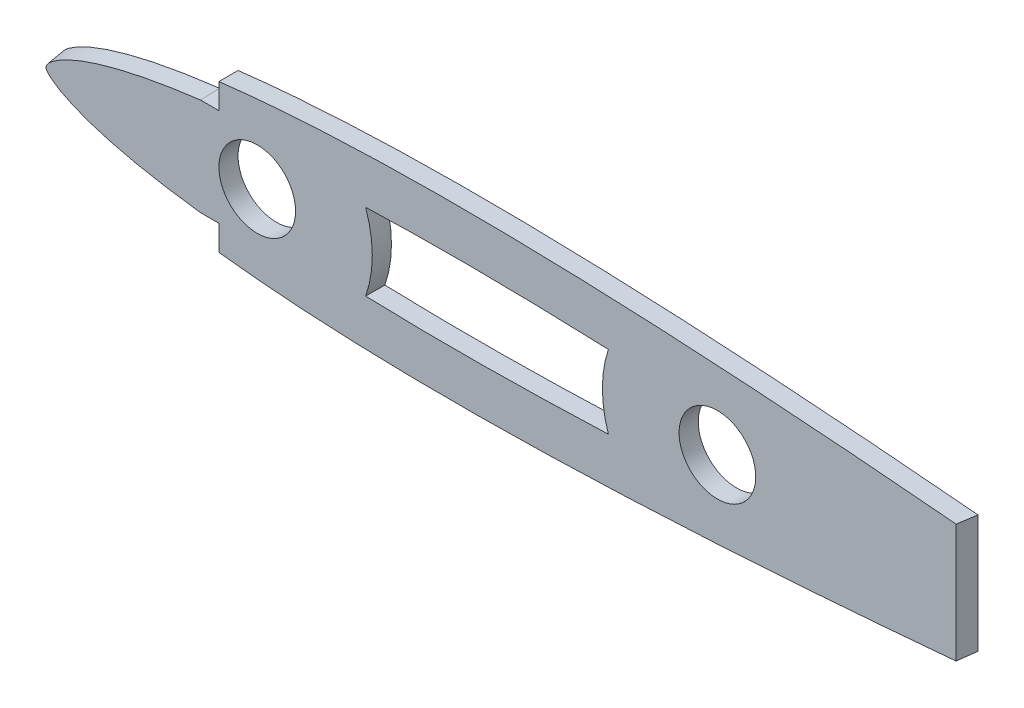
from build123d import *

# Parameters (mm, degrees)
BOSS_EXTRUDE1_DEPTH     = 3.175
SKETCH2_R               = 6.35
CUT_EXTRUDE1_DEPTH      = 3.175
CUT_EXTRUDE2_DEPTH      = 15.229125104
CUT_EXTRUDE2_DEPTH_BACK = 15.229125104
CUT_EXTRUDE3_DEPTH      = 7.62


with BuildPart() as part:
    # Sketch1 → Boss-Extrude1 (new body)
    with BuildSketch(Plane.XY):
        with BuildLine():
            add(Edge.make_bspline(
                [(237.0836, 0.298725336), (236.995594177, 0.372475408), (236.426976915, 0.302841036), (235.414414738, 0.587878253), (233.557510406, 0.764057302), (231.055978259, 1.142159154), (227.833630131, 1.564095564), (223.947681725, 2.084112793), (219.408243114, 2.671942868), (214.248186401, 3.326415443), (208.497669056, 4.03606524), (202.192664292, 4.791288168), (195.371926847, 5.582717259), (188.077459081, 6.399577403), (180.354259346, 7.2318954), (172.249998357, 8.069333754), (163.814621862, 8.901083193), (155.10015976, 9.715468455), (146.160279484, 10.50179834), (137.050196099, 11.246926821), (127.825887085, 11.938704549), (118.544307176, 12.564288117), (109.262643889, 13.110597113), (100.038037253, 13.563829729), (90.927458146, 13.911900095), (81.986813488, 14.143452851), (73.27135464, 14.247178081), (64.83463449, 14.214844108), (56.728667619, 14.040205364), (49.003349951, 13.718834947), (41.706232299, 13.249892202), (34.882163012, 12.634788148), (28.572900537, 11.878326773), (22.816901851, 10.986944444), (17.649046914, 9.969950888), (13.099625234, 8.838845522), (9.194488598, 7.604658034), (5.953477664, 6.278883166), (3.386928106, 4.870490409), (1.49878923, 3.376700029), (0.289451642, 1.761373844), (-0.134894757, 0), (0.289451642, -1.761373844), (1.49878923, -3.376700029), (3.386928106, -4.870490409), (5.953477664, -6.278883166), (9.194488598, -7.604658034), (13.099625234, -8.838845522), (17.649046914, -9.969950888), (22.816901851, -10.986944444), (28.572900537, -11.878326773), (34.882163012, -12.634788148), (41.706232299, -13.249892202), (49.003349951, -13.718834947), (56.728667619, -14.040205364), (64.83463449, -14.214844108), (73.27135464, -14.247178081), (81.986813488, -14.143452851), (90.927458146, -13.911900095), (100.038037253, -13.563829729), (109.262643889, -13.110597113), (118.544307176, -12.564288117), (127.825887085, -11.938704549), (137.050196099, -11.246926821), (146.160279484, -10.50179834), (155.10015976, -9.715468455), (163.814621862, -8.901083193), (172.249998357, -8.069333754), (180.354259346, -7.2318954), (188.077459081, -6.399577403), (195.371926847, -5.582717259), (202.192664292, -4.791288168), (208.497669056, -4.03606524), (214.248186401, -3.326415443), (219.408243114, -2.671942868), (223.947681725, -2.084112793), (227.833630131, -1.564095564), (231.055978259, -1.142159154), (233.557510406, -0.764057302), (235.414414738, -0.587878253), (236.426976915, -0.302841036), (237.226122795, -0.400706552), (237.226122795, 0.179289302), (237.0836, 0.298725336)],
                knots=[0, 0, 0, 0, 0.000762215, 0.003044706, 0.006832246, 0.012101176, 0.018817536, 0.026939455, 0.036414848, 0.047184629, 0.059180413, 0.072327874, 0.086544061, 0.10174058, 0.117823336, 0.134691452, 0.152240154, 0.17036129, 0.188941008, 0.207865435, 0.227016078, 0.246275696, 0.265524943, 0.284644966, 0.303520118, 0.322034575, 0.340078353, 0.357542593, 0.374325482, 0.390329891, 0.40546389, 0.419643801, 0.432793371, 0.444843817, 0.455737921, 0.465428653, 0.47388632, 0.481101634, 0.487101684, 0.491975368, 0.495930678, 0.499382808, 0.502834938, 0.506790248, 0.511663932, 0.517663982, 0.524879296, 0.533336963, 0.543027695, 0.553921799, 0.565972245, 0.579121815, 0.593301726, 0.608435725, 0.624440134, 0.641223023, 0.658687263, 0.676731041, 0.695245498, 0.71412065, 0.733240673, 0.75248992, 0.771749538, 0.790900181, 0.809824608, 0.828404326, 0.846525462, 0.864074164, 0.88094228, 0.897025036, 0.912221555, 0.926437743, 0.939585203, 0.951580988, 0.962350768, 0.971826161, 0.979948081, 0.98666444, 0.991933371, 0.99572091, 0.998003402, 0.998765616, 1, 1, 1, 1], degree=3))
        make_face()
    extrude(amount=BOSS_EXTRUDE1_DEPTH)

    # Sketch2 → Cut-Extrude1 (cut)
    with BuildSketch(Plane.XY.offset(3.175)):
        with Locations((38.1, 0)):
            Circle(SKETCH2_R)
        with Locations((114.3, 0)):
            Circle(SKETCH2_R)
    extrude(amount=-CUT_EXTRUDE1_DEPTH, mode=Mode.SUBTRACT)

    # Sketch3 → Cut-Extrude2 (cut, two sides)
    with BuildSketch(Plane(origin=(0, 0, 0), x_dir=(1, 0, 0), z_dir=(0, 1, 0))) as cut_extrude2_sk:
        Polygon((154.274292451, 0), (153.827643764, -3.175), (237.190492096, -3.175), (237.190492096, 0), align=None)
    extrude(amount=CUT_EXTRUDE2_DEPTH, mode=Mode.SUBTRACT)
    extrude(cut_extrude2_sk.sketch, amount=-CUT_EXTRUDE2_DEPTH_BACK, mode=Mode.SUBTRACT)

    # Sketch6 → Cut-Loft1 section 0
    with BuildSketch(Plane.XY.offset(3.175)):
        with BuildLine():
            Line((31.75, 8.076408981), (31.75, 11.683250037))
            Line((31.75, 11.683250037), (31.75, 18.395885889))
            Line((31.75, 18.395885889), (-8.998418256, 14.186873402))
            Line((-8.998418256, 14.186873402), (-8.032236021, -19.061162304))
            Line((-8.032236021, -19.061162304), (31.75, -17.664488176))
            Line((31.75, -17.664488176), (31.75, -11.683250037))
            Line((31.75, -11.683250037), (31.75, -8.076408982))
            Line((31.75, -8.076408982), (28.702, -8.076408982))
            add(Edge.make_bspline(
                [(28.702, 8.076408981), (28.062019842, 7.997428017), (26.781360323, 7.83190678), (24.863238423, 7.559576486), (22.952864289, 7.261817641), (21.053229662, 6.936585888), (19.16878625, 6.582266966), (17.301352642, 6.194891801), (15.452394184, 5.770523851), (13.933846318, 5.382610192), (12.734807014, 5.049324169), (11.845778194, 4.787008043), (10.968295358, 4.511299981), (10.104114856, 4.221132537), (9.254625692, 3.915388001), (8.425053114, 3.594578064), (7.620756036, 3.259288164), (6.846465326, 2.908873288), (6.109521351, 2.54404498), (5.415085904, 2.161886878), (4.771732283, 1.761162286), (4.200618093, 1.360175223), (3.806381168, 1.039757171), (3.546177048, 0.785599694), (3.383920596, 0.598121849), (3.254767765, 0.412598836), (3.174243399, 0.254294099), (3.130379566, 0.1138318), (3.117983008, 3.16e-07), (3.130380113, -0.113832551), (3.174242347, -0.254293127), (3.254769825, -0.41260053), (3.383916396, -0.598118576), (3.546175023, -0.785598191), (3.806491944, -1.039841143), (4.20055318, -1.360126113), (4.77176705, -1.761188423), (5.41506381, -2.161870561), (6.109540545, -2.544058683), (6.846443726, -2.908858743), (7.620785984, -3.259307593), (8.424980153, -3.594531648), (9.25458748, -3.915363972), (10.104136109, -4.221145998), (10.968310445, -4.511309444), (11.845765894, -4.787000103), (12.734797781, -5.049319704), (13.933888924, -5.382621972), (15.4523656, -5.770516248), (17.301363518, -6.194894525), (19.168788744, -6.582267832), (21.053210036, -6.936580559), (22.952903047, -7.261827785), (24.863140664, -7.559551063), (26.781311277, -7.831894211), (28.062019842, -7.997428017), (28.702, -8.076408982)],
                knots=[0, 0, 0, 0, 0.03125, 0.0625, 0.09375, 0.125, 0.15625, 0.1875, 0.21875, 0.25, 0.265625, 0.28125, 0.296875, 0.3125, 0.328125, 0.34375, 0.359375, 0.375, 0.390625, 0.40625, 0.421875, 0.4375, 0.453125, 0.4609375, 0.46875, 0.4765625, 0.484375, 0.4921875, 0.5, 0.5078125, 0.515625, 0.5234375, 0.53125, 0.5390625, 0.546875, 0.5625, 0.578125, 0.59375, 0.609375, 0.625, 0.640625, 0.65625, 0.671875, 0.6875, 0.703125, 0.71875, 0.734375, 0.75, 0.78125, 0.8125, 0.84375, 0.875, 0.90625, 0.9375, 0.96875, 1, 1, 1, 1], degree=3))
            Line((28.702, 8.076408981), (31.75, 8.076408981))
        make_face()
    # Sketch5 → Cut-Loft1 section 1
    with BuildSketch(Plane(origin=(0, 0, 0), x_dir=(-1, 0, 0), z_dir=(0, 0, -1))):
        with BuildLine():
            Line((-31.75, -11.773629767), (-31.75, -8.172962021))
            Line((-31.75, -8.172962021), (-28.702, -8.172962021))
            add(Edge.make_bspline(
                [(-28.702, 8.17296202), (-28.04991232, 8.094156153), (-26.745045473, 7.928885379), (-24.790625464, 7.656596528), (-22.843952156, 7.358509388), (-20.907993005, 7.032534185), (-18.987137813, 6.677003012), (-17.083250909, 6.287895965), (-15.197789513, 5.861217163), (-13.648800631, 5.470809812), (-12.425346674, 5.135128731), (-11.518003122, 4.870795331), (-10.622183079, 4.592820857), (-9.739660488, 4.300116815), (-8.871825969, 3.991542258), (-8.023884998, 3.667528855), (-7.201182529, 3.328585226), (-6.408478992, 2.973975846), (-5.653156453, 2.604323149), (-4.940474095, 2.216549268), (-4.279203879, 1.809302193), (-3.690786556, 1.400484278), (-3.283034517, 1.072052932), (-3.013354261, 0.810752852), (-2.845020129, 0.61774711), (-2.710958875, 0.426579544), (-2.627372313, 0.263337315), (-2.58177414, 0.117962243), (-2.568858472, 3.28e-07), (-2.581774708, -0.117963026), (-2.627371214, -0.263336298), (-2.710961028, -0.426581314), (-2.845015751, -0.617743699), (-3.01335214, -0.810751279), (-3.283150094, -1.072140545), (-3.690718878, -1.400433069), (-4.27924005, -1.809329397), (-4.940451244, -2.216532371), (-5.653176086, -2.604337198), (-6.408457303, -2.973961207), (-7.201212263, -3.32860454), (-8.023812968, -3.667483017), (-8.871788374, -3.991518624), (-9.739681391, -4.300130053), (-10.622197985, -4.592830206), (-11.517990976, -4.870787488), (-12.425337452, -5.135124325), (-13.648844495, -5.470821714), (-15.197759965, -5.861209465), (-17.083262354, -6.287898751), (-18.987139884, -6.677003815), (-20.907973868, -7.032528958), (-22.843990245, -7.358519372), (-24.790529171, -7.656571477), (-26.744997097, -7.928872987), (-28.04991232, -8.094156153), (-28.702, -8.172962021)],
                knots=[0, 0, 0, 0, 0.03125, 0.0625, 0.09375, 0.125, 0.15625, 0.1875, 0.21875, 0.25, 0.265625, 0.28125, 0.296875, 0.3125, 0.328125, 0.34375, 0.359375, 0.375, 0.390625, 0.40625, 0.421875, 0.4375, 0.453125, 0.4609375, 0.46875, 0.4765625, 0.484375, 0.4921875, 0.5, 0.5078125, 0.515625, 0.5234375, 0.53125, 0.5390625, 0.546875, 0.5625, 0.578125, 0.59375, 0.609375, 0.625, 0.640625, 0.65625, 0.671875, 0.6875, 0.703125, 0.71875, 0.734375, 0.75, 0.78125, 0.8125, 0.84375, 0.875, 0.90625, 0.9375, 0.96875, 1, 1, 1, 1], degree=3))
            Line((-28.702, 8.17296202), (-31.75, 8.17296202))
            Line((-31.75, 8.17296202), (-31.75, 11.773629767))
            Line((-31.75, 11.773629767), (-31.75, 14.858712547))
            Line((-31.75, 14.858712547), (1.815959964, 11.773629767))
            Line((1.815959964, 11.773629767), (0.454850161, -12.744594259))
            Line((0.454850161, -12.744594259), (-31.75, -15.902369002))
            Line((-31.75, -15.902369002), (-31.75, -11.773629767))
        make_face()
    loft(mode=Mode.SUBTRACT)

    # Sketch7 → Cut-Extrude3 (cut)
    with BuildSketch(Plane.XY.offset(3.175)):
        with BuildLine():
            ThreePointArc((56.054224621, -6.367756139), (57.15, 0), (56.054224621, 6.367756139))
            add(Edge.make_bspline(
                [(96.245779506, 6.07845559), (93.861405197, 6.172308422), (91.477846396, 6.255305153), (84.344598798, 6.468290826), (79.598726683, 6.562324228), (70.121487659, 6.629056545), (65.389943722, 6.602176751), (59.131701158, 6.462519155), (57.592019112, 6.419793098), (56.054224621, 6.367756139)],
                knots=[0.437309704, 0.437309704, 0.437309704, 0.437309704, 0.5, 0.5, 0.625, 0.625, 0.75, 0.75, 0.790835922, 0.790835922, 0.790835922, 0.790835922], degree=3))
            ThreePointArc((96.245779506, 6.07845559), (95.25, 0), (96.245779506, -6.07845559))
            add(Edge.make_bspline(
                [(56.054224621, -6.367756139), (57.592019112, -6.419793098), (59.131701158, -6.462519155), (65.389943722, -6.602176751), (70.121487659, -6.629056545), (79.598726683, -6.562324228), (84.344598798, -6.468290826), (91.477846396, -6.255305153), (93.861405197, -6.172308422), (96.245779506, -6.07845559)],
                knots=[0.209164078, 0.209164078, 0.209164078, 0.209164078, 0.25, 0.25, 0.375, 0.375, 0.5, 0.5, 0.562690296, 0.562690296, 0.562690296, 0.562690296], degree=3))
        make_face()
    extrude(amount=-CUT_EXTRUDE3_DEPTH, mode=Mode.SUBTRACT)


solid = part.part
